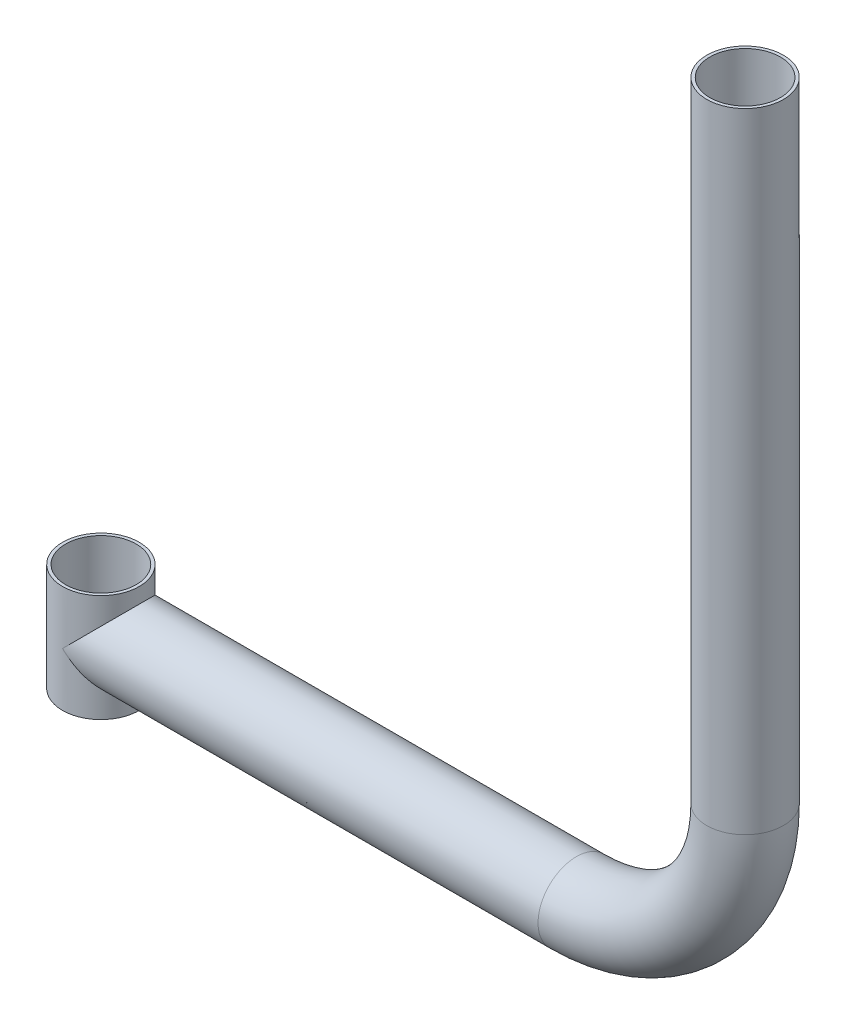
from build123d import *

# Parameters (mm, degrees)
SKETCH_1_R          = 12.5
SKETCH_1_R_2        = 11.5
EXTRUDE_1_DEPTH     = 17.5
SKETCH_2_R          = 12.5
SKETCH_2_R_2        = 11.5
SKETCH_1_3_R        = 11.5
CUT_EXTRUDE_2_DEPTH = 400


with BuildPart() as part:
    # 草圖1 → 填料-伸長1 (new, symmetric)
    with BuildSketch(Plane(origin=(0, 0, 0), x_dir=(1, 0, 0), z_dir=(0, 1, 0))):
        Circle(SKETCH_1_R)
        Circle(SKETCH_1_R_2, mode=Mode.SUBTRACT)
    extrude(amount=EXTRUDE_1_DEPTH, both=True)

    # 掃出1: sweep along a path in 草圖6
    with BuildLine(Plane.XY) as sweep_1_path:
        Line((0, 0), (155, 0))
        ThreePointArc((155, 0), (193.890872965, 16.109127035), (210, 55))
        Line((210, 55), (210, 260))
    # 草圖2 → 掃出1 (sweep)
    with BuildSketch(Plane(origin=(0, 0, 0), x_dir=(0, 0, -1), z_dir=(1, 0, 0))):
        Circle(SKETCH_2_R)
        Circle(SKETCH_2_R_2, mode=Mode.SUBTRACT)
    sweep(path=sweep_1_path.line)

    # 草圖1<3> → 除料-伸長2 (cut, symmetric)
    with BuildSketch(Plane(origin=(0, 0, 0), x_dir=(1, 0, 0), z_dir=(0, 1, 0))):
        Circle(SKETCH_1_3_R)
    extrude(amount=CUT_EXTRUDE_2_DEPTH, both=True, mode=Mode.SUBTRACT)


solid = part.part
